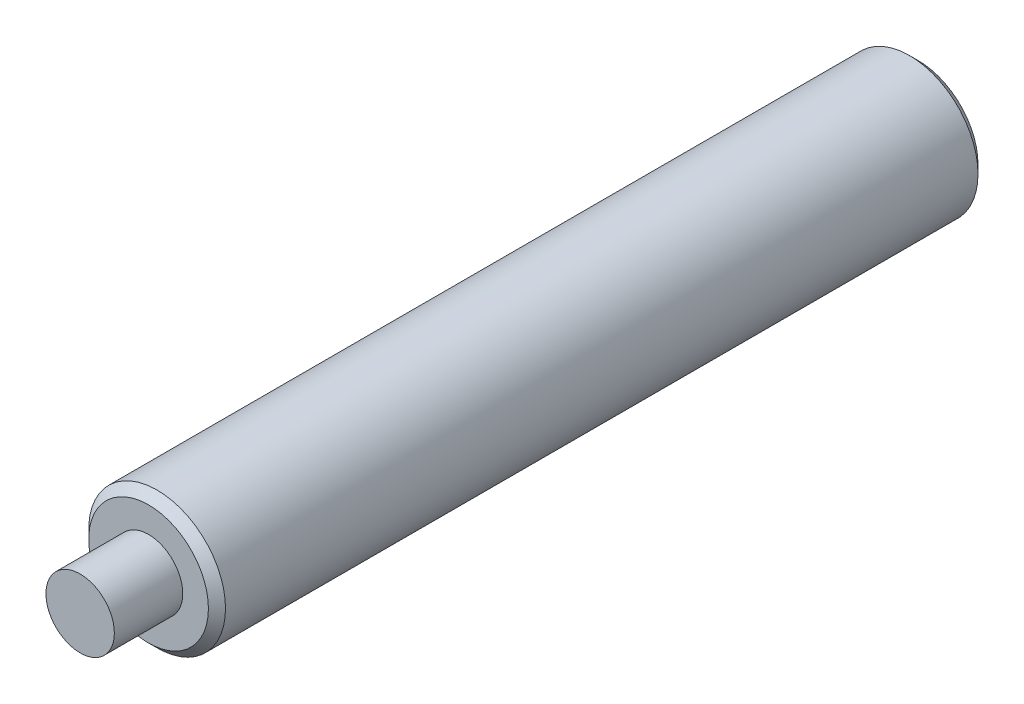
from build123d import *

# Parameters (mm, degrees)
ESQUISSE1_R          = 4
BASE_EXTRUSION_DEPTH = 45
CHANFREIN1_SIZE      = 0.5
ESQUISSE2_R          = 2
BOSS_EXTRU_1_DEPTH   = 4


with BuildPart() as part:
    # Esquisse1 → Base-Extrusion (new body)
    with BuildSketch(Plane.XY):
        Circle(ESQUISSE1_R)
    extrude(amount=BASE_EXTRUSION_DEPTH)

    # Chanfrein1
    chanfrein1_edges = [part.edges().sort_by_distance(p)[0] for p in [
        (-4, 0, 0),
        (-4, 0, 45),
    ]]
    chamfer(chanfrein1_edges, length=CHANFREIN1_SIZE)

    # Esquisse2 → Boss.-Extru.1 (add)
    with BuildSketch(Plane.XY.offset(45)):
        Circle(ESQUISSE2_R)
    extrude(amount=BOSS_EXTRU_1_DEPTH)


solid = part.part
